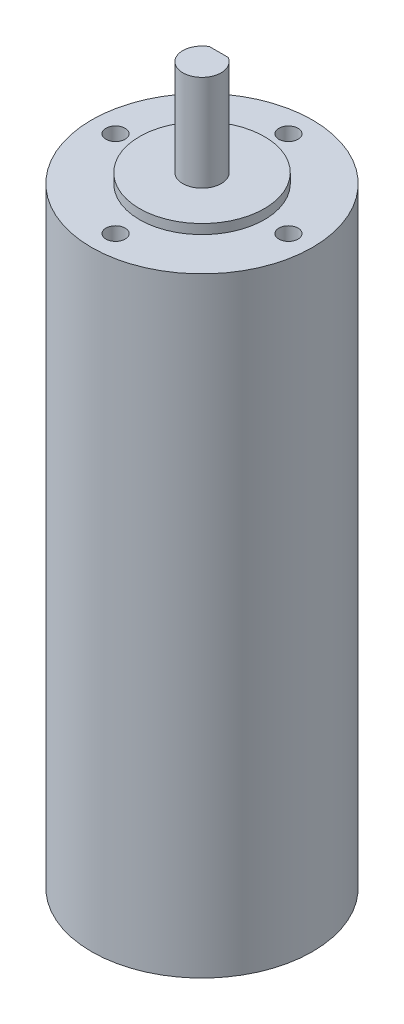
from build123d import *

# Parameters (mm, degrees)
SKETCH2_R           = 23
BOSS_EXTRUDE1_DEPTH = 127
SKETCH3_R           = 13
BOSS_EXTRUDE2_DEPTH = 2
SKETCH4_R           = 4
BOSS_EXTRUDE3_DEPTH = 20
SKETCH8_R           = 2
CUT_EXTRUDE1_DEPTH  = 10
CUT_EXTRUDE2_DEPTH  = 12


with BuildPart() as part:
    # Sketch2 → Boss-Extrude1 (new body)
    with BuildSketch(Plane(origin=(0, 0, 0), x_dir=(1, 0, 0), z_dir=(0, 1, 0))):
        Circle(SKETCH2_R)
    extrude(amount=BOSS_EXTRUDE1_DEPTH)

    # Sketch3 → Boss-Extrude2 (add)
    with BuildSketch(Plane(origin=(0, 127, 0), x_dir=(1, 0, 0), z_dir=(0, 1, 0))):
        Circle(SKETCH3_R)
    extrude(amount=BOSS_EXTRUDE2_DEPTH)

    # Sketch4 → Boss-Extrude3 (add)
    with BuildSketch(Plane(origin=(0, 129, 0), x_dir=(1, 0, 0), z_dir=(0, 1, 0))):
        Circle(SKETCH4_R)
    extrude(amount=BOSS_EXTRUDE3_DEPTH)

    # Sketch8 → Cut-Extrude1 (cut)
    with BuildSketch(Plane(origin=(0, 127, 0), x_dir=(1, 0, 0), z_dir=(0, 1, 0))):
        with Locations((0, 18)):
            Circle(SKETCH8_R)
        with Locations((18, 0)):
            Circle(SKETCH8_R)
        with Locations((0, -18)):
            Circle(SKETCH8_R)
        with Locations((-18, 0)):
            Circle(SKETCH8_R)
    extrude(amount=-CUT_EXTRUDE1_DEPTH, mode=Mode.SUBTRACT)

    # Sketch10 → Cut-Extrude2 (cut)
    with BuildSketch(Plane(origin=(0, 149, 0), x_dir=(1, 0, 0), z_dir=(0, 1, 0))):
        Polygon((-84.712273825, 3.5), (-1.936491673, 3.5), (1.936491673, 3.5), (84.712273825, 3.5), (84.712273825, 169.051564304), (-84.712273825, 169.051564304), align=None)
    extrude(amount=-CUT_EXTRUDE2_DEPTH, mode=Mode.SUBTRACT)


solid = part.part
